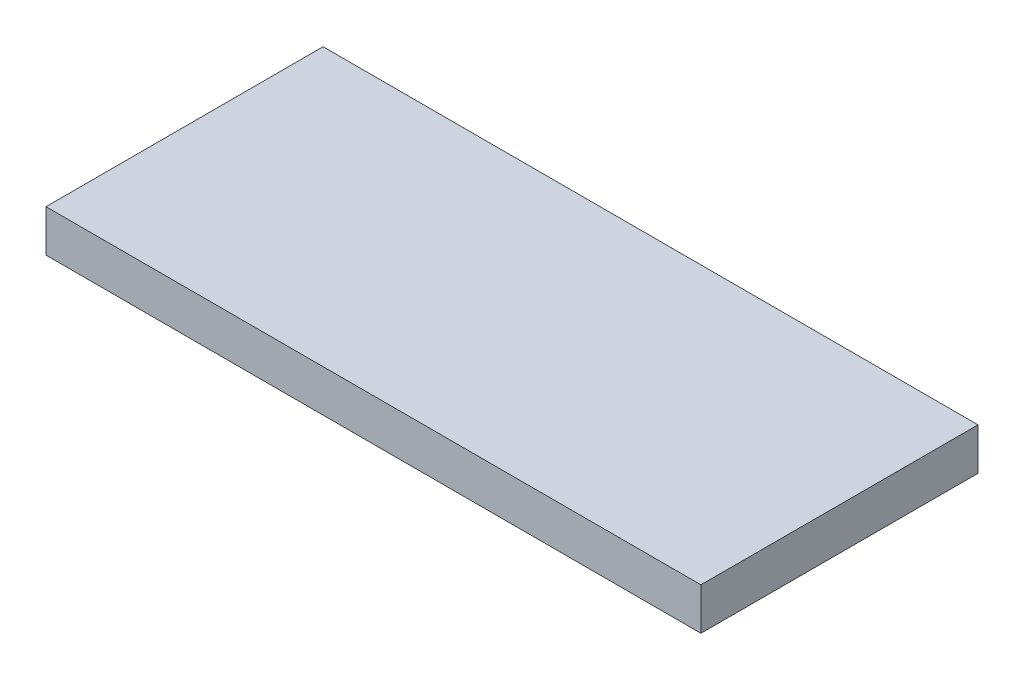
from build123d import *

# Parameters (mm, degrees)
SKETCH_1_W      = 78
SKETCH_1_H      = 33
EXTRUDE_1_DEPTH = 5


with BuildPart() as part:
    # Эскиз1 → Бобышка-Вытянуть1 (new body)
    with BuildSketch(Plane(origin=(0, 0, 0), x_dir=(1, 0, 0), z_dir=(0, 1, 0))):
        with Locations((39, 16.5)):
            Rectangle(SKETCH_1_W, SKETCH_1_H)
    extrude(amount=EXTRUDE_1_DEPTH)


solid = part.part
